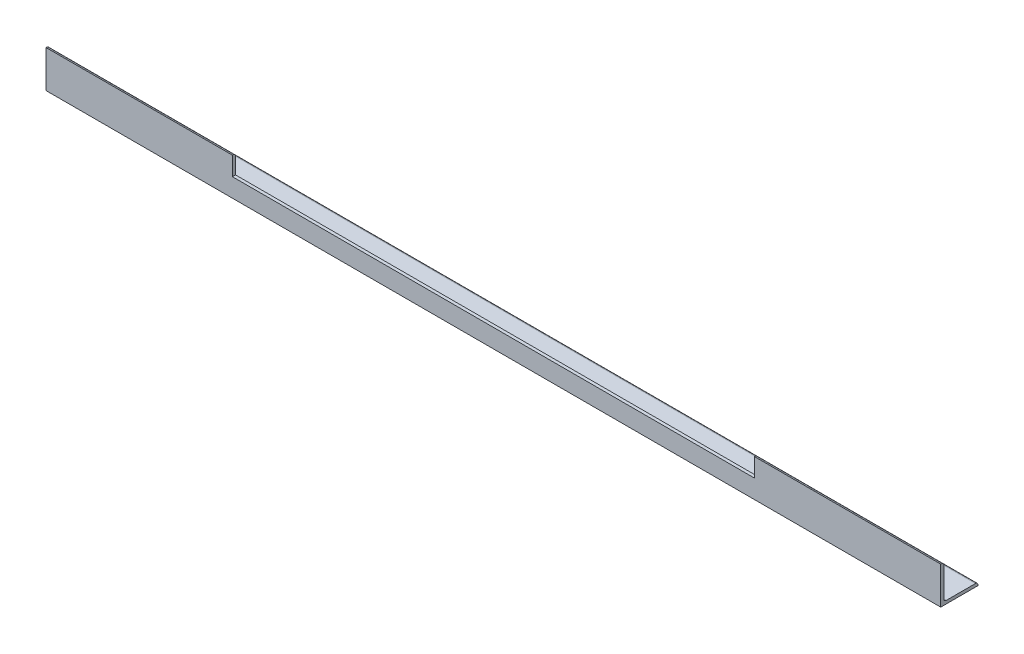
from build123d import *

# Parameters (mm, degrees)
BOSS_EXTRUDE1_DEPTH      = 914.4
BOSS_EXTRUDE1_DEPTH_BACK = 914.4
SKETCH2_W                = 1066.8
SKETCH2_H                = 38.1
CUT_EXTRUDE1_DEPTH       = 921.728103188


with BuildPart() as part:
    # Sketch1 → Boss-Extrude1 (new, two sides: drawn at the far end of the back side and taken through both)
    with BuildSketch(Plane(origin=(0, 0, 0), x_dir=(0, 0, -1), z_dir=(1, 0, 0)).offset(-BOSS_EXTRUDE1_DEPTH_BACK)):
        with BuildLine():
            Line((0, 76.2), (0, 0))
            Line((0, 0), (76.2, 0))
            Line((76.2, 0), (76.2, 1.27))
            ThreePointArc((76.2, 1.27), (74.712102448, 4.862102448), (71.12, 6.35))
            Line((71.12, 6.35), (11.43, 6.35))
            ThreePointArc((11.43, 6.35), (7.837897552, 7.837897552), (6.35, 11.43))
            Line((6.35, 11.43), (6.35, 71.12))
            ThreePointArc((6.35, 71.12), (4.862102448, 74.712102448), (1.27, 76.2))
            Line((1.27, 76.2), (0, 76.2))
        make_face()
    extrude(amount=BOSS_EXTRUDE1_DEPTH + BOSS_EXTRUDE1_DEPTH_BACK)

    # Sketch2 → Cut-Extrude1 (cut, through all)
    with BuildSketch(Plane.XY):
        with Locations((0, 57.15)):
            Rectangle(SKETCH2_W, SKETCH2_H)
    extrude(amount=-CUT_EXTRUDE1_DEPTH, mode=Mode.SUBTRACT)


solid = part.part
